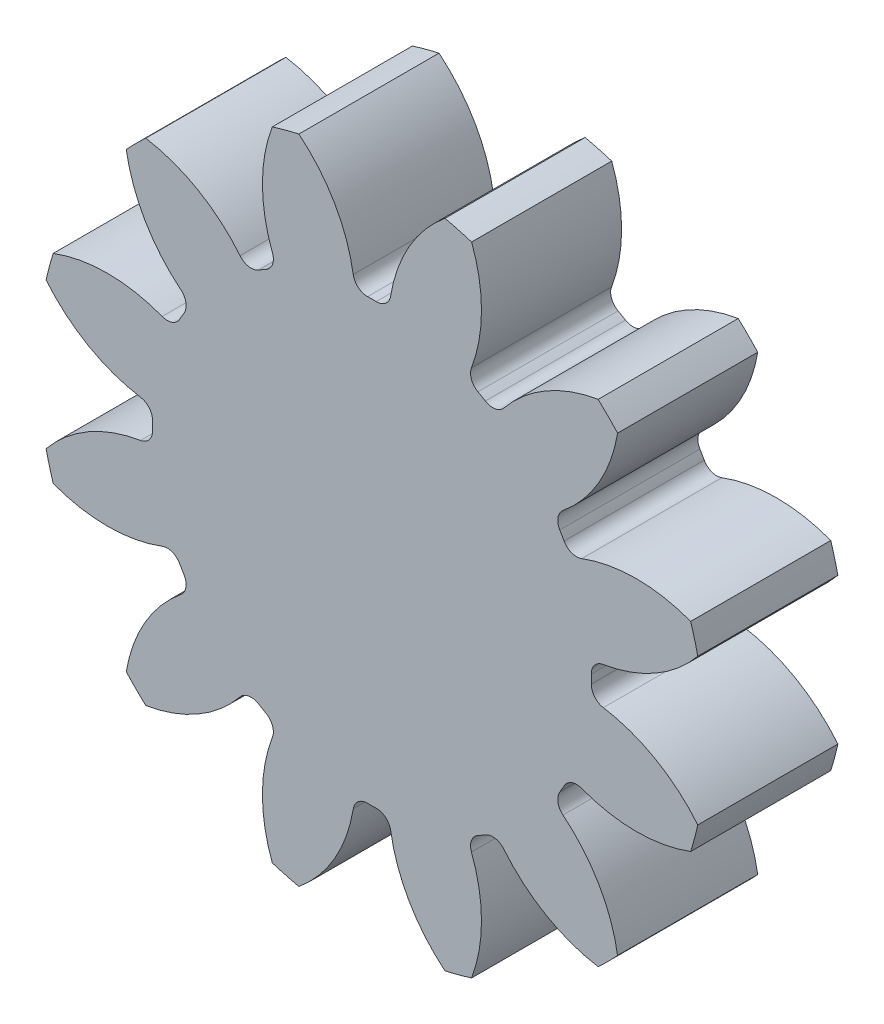
from build123d import *

# Parameters (mm, degrees)
SKETCH2_R                = 7.15
BOSS_EXTRUDE1_DEPTH      = 1.5
CUT_EXTRUDE1_DEPTH       = 2.5
FILLET1_R                = 0.306428571
CIRPATTERN1_COUNT        = 12
FILLET1_OF_CIRPATTERN1_R = 0.306428571


with BuildPart() as part:
    # Sketch2 → Boss-Extrude1 (new body, symmetric)
    with BuildSketch(Plane.XY):
        Circle(SKETCH2_R)
    extrude(amount=BOSS_EXTRUDE1_DEPTH, both=True)

    # Sketch3 → Cut-Extrude1 (cut, symmetric)
    with BuildSketch(Plane.XY):
        with BuildLine():
            ThreePointArc((-0.367845015, 4.684150245), (-1.14077064, 6.560276119), (-2.865133916, 7.629777693))
            ThreePointArc((-2.865133916, 7.629777693), (0, 8.15), (2.865133916, 7.629777693))
            ThreePointArc((2.865133916, 7.629777693), (1.14077064, 6.560276119), (0.367845015, 4.684150245))
            ThreePointArc((0.367845015, 4.684150245), (0, 4.698571429), (-0.367845015, 4.684150245))
        make_face()
    cut_extrude1 = extrude(amount=CUT_EXTRUDE1_DEPTH, both=True, mode=Mode.SUBTRACT)

    # Fillet1
    fillet1_edges = [part.edges().sort_by_distance(p)[0] for p in [
        (-0.367845015, 4.684150245, 0),
        (0.367845015, 4.684150245, 0),
    ]]
    fillet(fillet1_edges, radius=FILLET1_R)

    # CirPattern1: Cut-Extrude1 ×12 about axis
    cirpattern1_axis = Axis((0, 0, 0), (0, 0, 1))
    for i in range(1, CIRPATTERN1_COUNT):
        add(cut_extrude1.rotate(cirpattern1_axis, i * 360 / CIRPATTERN1_COUNT), mode=Mode.SUBTRACT)

    # Fillet1 of CirPattern1
    fillet1_of_cirpattern1_edges = [part.edges().sort_by_distance(p)[0] for p in [
        (-2.66063825, 3.8726706, 0),
        (-2.023511995, 4.240515614, 0),
        (-4.240515614, 2.023511995, 0),
        (-3.8726706, 2.66063825, 0),
        (-4.684150245, -0.367845015, 0),
        (-4.684150245, 0.367845015, 0),
        (-3.8726706, -2.66063825, 0),
        (-4.240515614, -2.023511995, 0),
        (-2.023511995, -4.240515614, 0),
        (-2.66063825, -3.8726706, 0),
        (0.367845015, -4.684150245, 0),
        (-0.367845015, -4.684150245, 0),
        (2.66063825, -3.8726706, 0),
        (2.023511995, -4.240515614, 0),
        (4.240515614, -2.023511995, 0),
        (3.8726706, -2.66063825, 0),
        (4.684150245, 0.367845015, 0),
        (4.684150245, -0.367845015, 0),
        (3.8726706, 2.66063825, 0),
        (4.240515614, 2.023511995, 0),
        (2.023511995, 4.240515614, 0),
        (2.66063825, 3.8726706, 0),
    ]]
    fillet(fillet1_of_cirpattern1_edges, radius=FILLET1_OF_CIRPATTERN1_R)


solid = part.part
